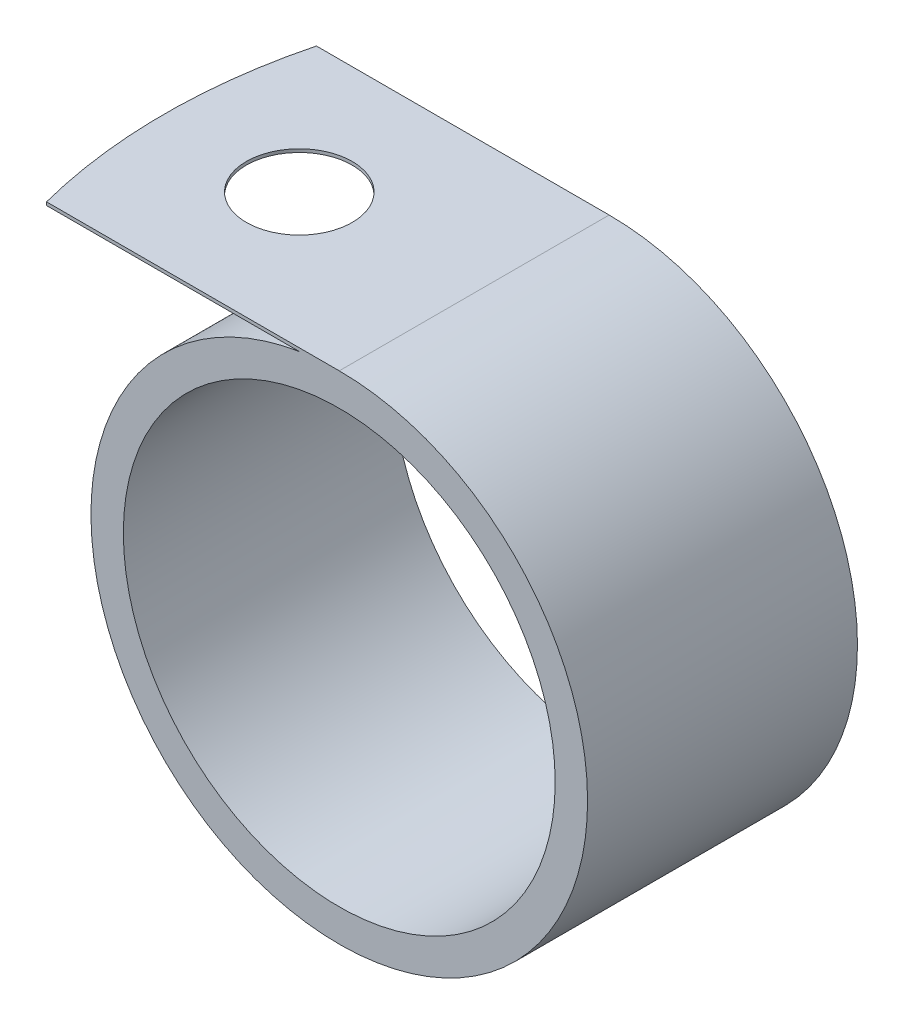
from build123d import *

# Parameters (mm, degrees)
SKETCH1_R           = 10.16
BOSS_EXTRUDE1_DEPTH = 6.35
CUT_EXTRUDE1_REACH  = 25.368
SKETCH2_R           = 2.4892


with BuildPart() as part:
    # Sketch1 → Boss-Extrude1 (new body, symmetric)
    with BuildSketch(Plane.XY):
        with BuildLine():
            Line((0, 11.684), (-14.580972472, 11.684))
            Line((-14.580972472, 11.684), (-14.580972472, 11.5316))
            Line((-14.580972472, 11.5316), (-1.880972472, 11.5316))
            ThreePointArc((-1.880972472, 11.5316), (0.943568122, -11.645837677), (0, 11.684))
        make_face()
        Circle(SKETCH1_R, mode=Mode.SUBTRACT)
    extrude(amount=BOSS_EXTRUDE1_DEPTH, both=True)

    # Sketch2 → Cut-Extrude1 (cut, up to next)
    with BuildSketch(Plane(origin=(0, 11.684, 0), x_dir=(1, 0, 0), z_dir=(0, 1, 0)), mode=Mode.PRIVATE) as cut_extrude1_sk1:
        with Locations((-8.230972472, 0)):
            Circle(SKETCH2_R)
    cut_extrude1_tool1 = extrude(cut_extrude1_sk1.sketch, amount=-CUT_EXTRUDE1_REACH, mode=Mode.PRIVATE) & part.part
    add(cut_extrude1_tool1.solids().sort_by_distance((-8.230972, 11.684, 0))[0], mode=Mode.SUBTRACT)
    # Sketch2 → Cut-Extrude1 (cut, up to next)
    with BuildSketch(Plane(origin=(0, 11.684, 0), x_dir=(1, 0, 0), z_dir=(0, 1, 0)), mode=Mode.PRIVATE) as cut_extrude1_sk2:
        with BuildLine():
            ThreePointArc((-14.580972472, 0), (-14.378526757, 3.200509029), (-13.77441672, 6.35))
            Line((-13.77441672, 6.35), (-14.580972472, 6.35))
            Line((-14.580972472, 6.35), (-14.580972472, 0))
        make_face()
    cut_extrude1_tool2 = extrude(cut_extrude1_sk2.sketch, amount=-CUT_EXTRUDE1_REACH, mode=Mode.PRIVATE) & part.part
    add(cut_extrude1_tool2.solids().sort_by_distance((-14.339679, 11.684, -4.767585))[0], mode=Mode.SUBTRACT)
    # Sketch2 → Cut-Extrude1 (cut, up to next)
    with BuildSketch(Plane(origin=(0, 11.684, 0), x_dir=(1, 0, 0), z_dir=(0, 1, 0)), mode=Mode.PRIVATE) as cut_extrude1_sk3:
        with BuildLine():
            ThreePointArc((-13.77441672, -6.35), (-14.378526757, -3.200509029), (-14.580972472, 0))
            Line((-14.580972472, 0), (-14.580972472, -6.35))
            Line((-14.580972472, -6.35), (-13.77441672, -6.35))
        make_face()
    cut_extrude1_tool3 = extrude(cut_extrude1_sk3.sketch, amount=-CUT_EXTRUDE1_REACH, mode=Mode.PRIVATE) & part.part
    add(cut_extrude1_tool3.solids().sort_by_distance((-14.339679, 11.684, 4.767585))[0], mode=Mode.SUBTRACT)


solid = part.part
